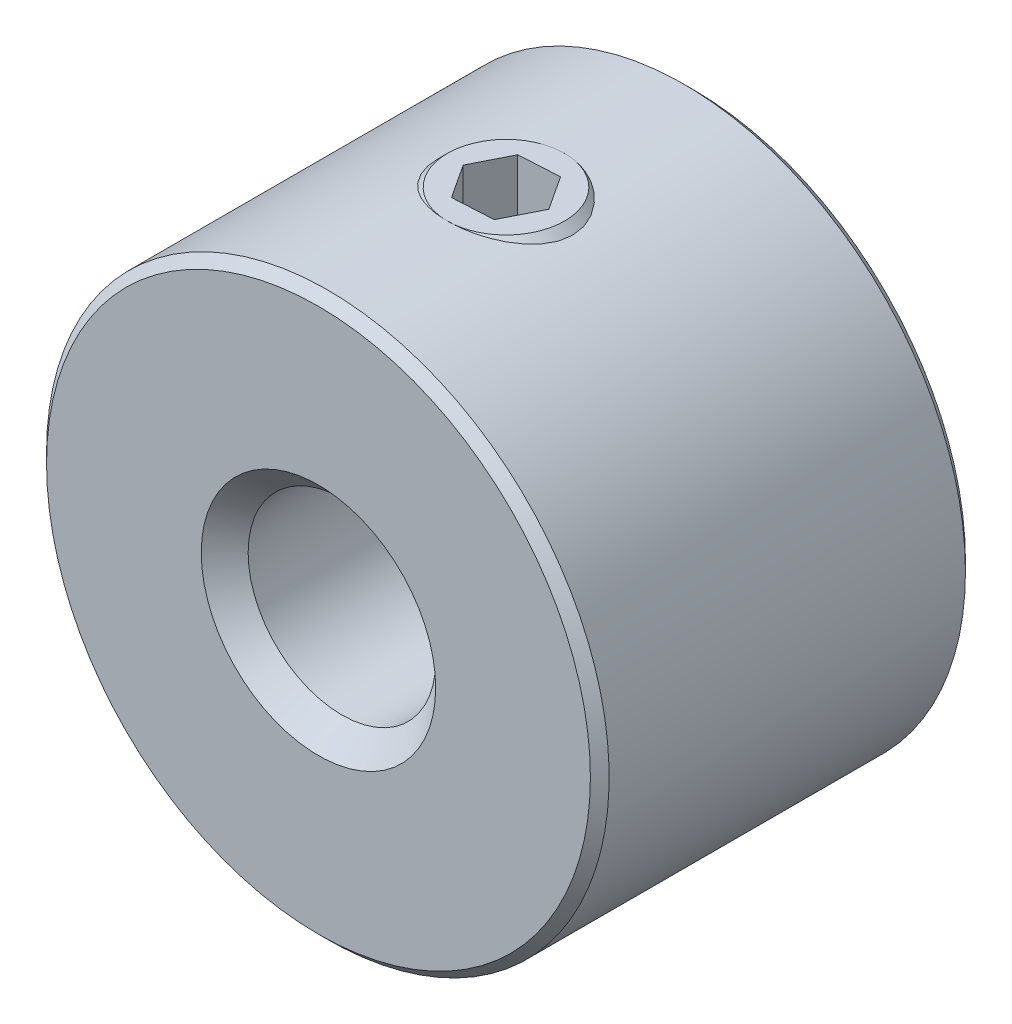
from build123d import *

# Parameters (mm, degrees)
SKETCH1_W           = 4
SKETCH1_H           = 8
SKETCH2_R           = 1.25
CUT_EXTRUDE1_DEPTH  = 12.66190379
CHAMFER1_SIZE       = 0.2
SKETCH4_R           = 1.5
BOSS_EXTRUDE1_DEPTH = 4.5
CHAMFER2_SIZE       = 0.25
CUT_EXTRUDE3_DEPTH  = 2
CHAMFER3_SIZE       = 0.5


with BuildPart() as part:
    # Sketch1 → Revolve1 (revolve)
    with BuildSketch(Plane(origin=(0, 0, 0), x_dir=(1, 0, 0), z_dir=(0, 1, 0))):
        with Locations((4, -4)):
            Rectangle(SKETCH1_W, SKETCH1_H)
    revolve(axis=Axis((0, 0, -122.457916377), (0, 0, 1)))

    # Sketch2 → Cut-Extrude1 (cut, through all)
    with BuildSketch(Plane(origin=(0, 0, 0), x_dir=(1, 0, 0), z_dir=(0, 1, 0))):
        with Locations((0, -4)):
            Circle(SKETCH2_R)
    extrude(amount=CUT_EXTRUDE1_DEPTH, mode=Mode.SUBTRACT)

    # Chamfer1
    chamfer1_edges = [part.edges().sort_by_distance(p)[0] for p in [
        (-6, 0, 8),
        (-6, 0, 0),
    ]]
    chamfer(chamfer1_edges, length=CHAMFER1_SIZE)

    # Chamfer3
    chamfer3_edges = [part.edges().sort_by_distance(p)[0] for p in [
        (-2, 0, 0),
        (-2, 0, 8),
    ]]
    chamfer(chamfer3_edges, length=CHAMFER3_SIZE)


with BuildPart() as body_2:
    # Sketch4 → Boss-Extrude1 (new body)
    with BuildSketch(Plane(origin=(0, 1.5, 0), x_dir=(1, 0, 0), z_dir=(0, 1, 0))):
        with Locations((0, -4)):
            Circle(SKETCH4_R)
    extrude(amount=BOSS_EXTRUDE1_DEPTH)

    # Chamfer2
    chamfer2_edges = [body_2.edges().sort_by_distance(p)[0] for p in [
        (-1.5, 6, 4),
    ]]
    chamfer(chamfer2_edges, length=CHAMFER2_SIZE)

    # Sketch5 → Cut-Extrude3 (cut)
    with BuildSketch(Plane(origin=(0, 6, 0), x_dir=(1, 0, 0), z_dir=(0, 1, 0))):
        Polygon((0.4745541, -4.724429711), (0.864651583, -3.951238949), (0.390097483, -3.226809238), (-0.4745541, -3.275570289), (-0.864651583, -4.048761051), (-0.390097483, -4.773190762), align=None)
    extrude(amount=-CUT_EXTRUDE3_DEPTH, mode=Mode.SUBTRACT)


solid = Compound([part.part, body_2.part])
